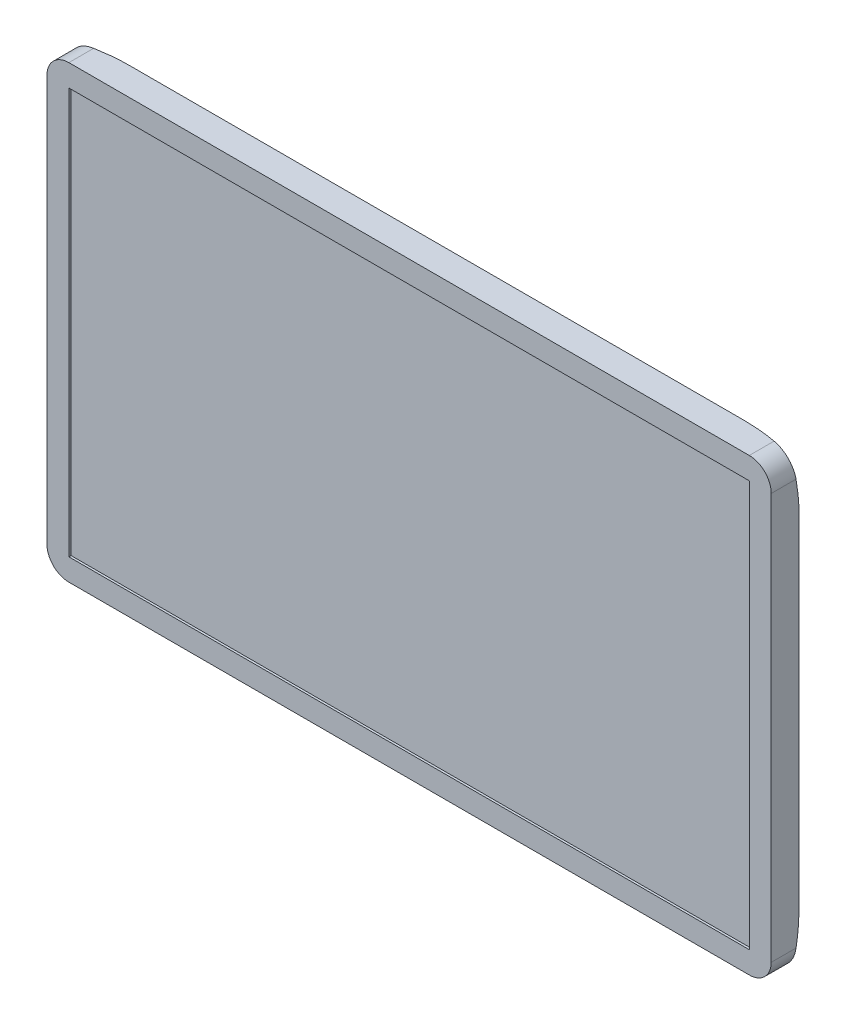
from build123d import *

# Parameters (mm, degrees)
ESQUISSE1_W             = 330
ESQUISSE1_H             = 205
BOSS_EXTRU_1_DEPTH      = 30
CHANFREIN1_SIZE         = 30
CHANFREIN1_SIZE2        = 17.320508076
CONG_1_R                = 50
CONG_3_R                = 10
ESQUISSE2_W             = 310
ESQUISSE2_H             = 185
ENL_V_MAT_EXTRU_1_DEPTH = 1
D_GAGEMENT_M42_D        = 4
D_GAGEMENT_M42_DEPTH    = 10
D_GAGEMENT_M42_TIP      = 1.201721238
D_GAGEMENT_M71_D        = 7
D_GAGEMENT_M71_DEPTH    = 5
D_GAGEMENT_M71_TIP      = 2.103012167
ENL_V_MAT_EXTRU_2_DEPTH = 17.320508


with BuildPart() as part:
    # Esquisse1 → Boss.-Extru.1 (new body)
    with BuildSketch(Plane.XY):
        with Locations((165, 102.5)):
            Rectangle(ESQUISSE1_W, ESQUISSE1_H)
    extrude(amount=BOSS_EXTRU_1_DEPTH)

    # Chanfrein1
    chanfrein1_edges = [part.edges().sort_by_distance(p)[0] for p in [
        (165, 205, 0),
        (330, 102.5, 0),
        (165, 0, 0),
        (0, 102.5, 0),
    ]]
    chanfrein1_side = [part.faces().sort_by_distance(p)[0] for p in [
        (165, 102.5, 0),
    ]]
    chamfer(chanfrein1_edges, length=CHANFREIN1_SIZE, length2=CHANFREIN1_SIZE2, reference=chanfrein1_side[0])

    # Congé1
    cong_1_edges = [part.edges().sort_by_distance(p)[0] for p in [
        (315, 15, 8.660254038),
        (15, 15, 8.660254038),
        (315, 190, 8.660254038),
        (15, 190, 8.660254038),
    ]]
    fillet(cong_1_edges, radius=CONG_1_R)

    # Congé3
    cong_3_edges = [part.edges().sort_by_distance(p)[0] for p in [
        (0, 205, 25.524681254),
        (330, 205, 25.524681254),
        (330, 0, 25.524681254),
        (0, 0, 25.524681254),
    ]]
    fillet(cong_3_edges, radius=CONG_3_R)

    # Esquisse2 → Enlèv. mat.-Extru.1 (cut)
    with BuildSketch(Plane.XY.offset(30)):
        with Locations((165, 102.5)):
            Rectangle(ESQUISSE2_W, ESQUISSE2_H)
    extrude(amount=-ENL_V_MAT_EXTRU_1_DEPTH, mode=Mode.SUBTRACT)

    # Dégagement M42
    with Locations(Plane(origin=(0, 0, 0), x_dir=(-1, 0, 0), z_dir=(0, 0, -1))):
        with Locations((-202.5, 65), (-127.5, 140), (-127.5, 65), (-202.5, 140)):
            Hole(D_GAGEMENT_M42_D / 2, depth=D_GAGEMENT_M42_DEPTH)
            with Locations((0, 0, -(D_GAGEMENT_M42_DEPTH + D_GAGEMENT_M42_TIP / 2))):  # 118° drill point
                Cone(0, D_GAGEMENT_M42_D / 2, D_GAGEMENT_M42_TIP, mode=Mode.SUBTRACT)

    # Dégagement M71
    with Locations(Plane(origin=(0, 0, 0), x_dir=(-1, 0, 0), z_dir=(0, 0, -1))):
        with Locations((-215, 152.5), (-115, 152.5), (-165, 42.313793967)):
            Hole(D_GAGEMENT_M71_D / 2, depth=D_GAGEMENT_M71_DEPTH)
            with Locations((0, 0, -(D_GAGEMENT_M71_DEPTH + D_GAGEMENT_M71_TIP / 2))):  # 118° drill point
                Cone(0, D_GAGEMENT_M71_D / 2, D_GAGEMENT_M71_TIP, mode=Mode.SUBTRACT)

    # Esquisse9 → Enlèv. mat.-Extru.2 (cut)
    with BuildSketch(Plane(origin=(0, 0, 0), x_dir=(-1, 0, 0), z_dir=(0, 0, -1))):
        with BuildLine():
            Line((-330, 180), (-297.928932188, 147.928932188))
            ThreePointArc((-297.928932188, 147.928932188), (-295.761204675, 144.6846987), (-295, 140.857864376))
            Line((-295, 140.857864376), (-295, 64.142135624))
            ThreePointArc((-295, 64.142135624), (-295.761204675, 60.3153013), (-297.928932188, 57.071067812))
            Line((-297.928932188, 57.071067812), (-330, 25))
            Line((-330, 25), (-330, 180))
        make_face()
    extrude(amount=-ENL_V_MAT_EXTRU_2_DEPTH, mode=Mode.SUBTRACT)


solid = part.part
